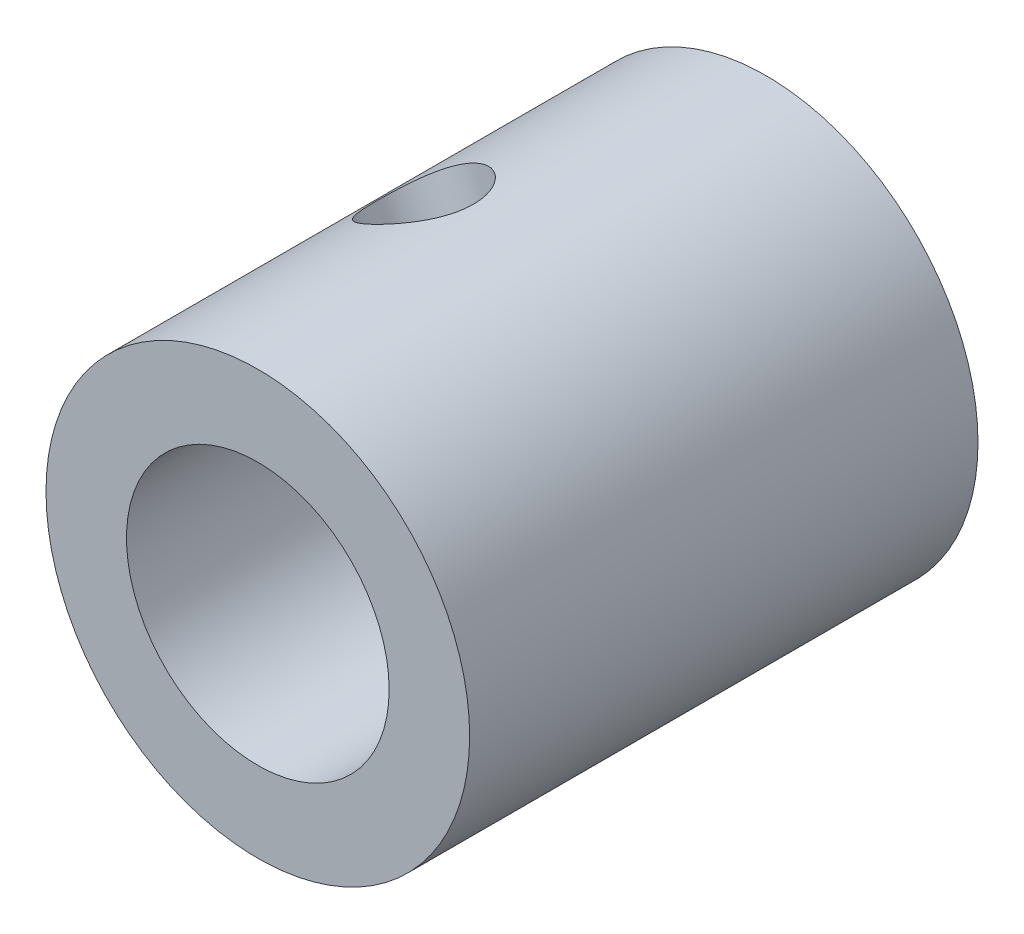
from build123d import *

# Parameters (mm, degrees)
SKETCH_1_R      = 5
SKETCH_1_R_2    = 3.1
EXTRUDE_1_DEPTH = 12
M3X0_5_1_D      = 2.5
M3X0_5_1_DEPTH  = 4
M3X0_5_1_TIP    = 0.751075774


with BuildPart() as part:
    # ｽｹｯﾁ1 → ﾎﾞｽ - 押し出し1 (new body)
    with BuildSketch(Plane.XY):
        Circle(SKETCH_1_R)
        Circle(SKETCH_1_R_2, mode=Mode.SUBTRACT)
    extrude(amount=EXTRUDE_1_DEPTH)

    # M3x0.5 ねじ穴1
    with Locations(Plane(origin=(-2.109966483, 4.532994754, 6), x_dir=(0.906598951, 0.421993297, 0), z_dir=(-0.421993297, 0.906598951, 0))):
        with Locations((0, 0)):
            Hole(M3X0_5_1_D / 2, depth=M3X0_5_1_DEPTH)
            with Locations((0, 0, -(M3X0_5_1_DEPTH + M3X0_5_1_TIP / 2))):  # 118° drill point
                Cone(0, M3X0_5_1_D / 2, M3X0_5_1_TIP, mode=Mode.SUBTRACT)


solid = part.part
